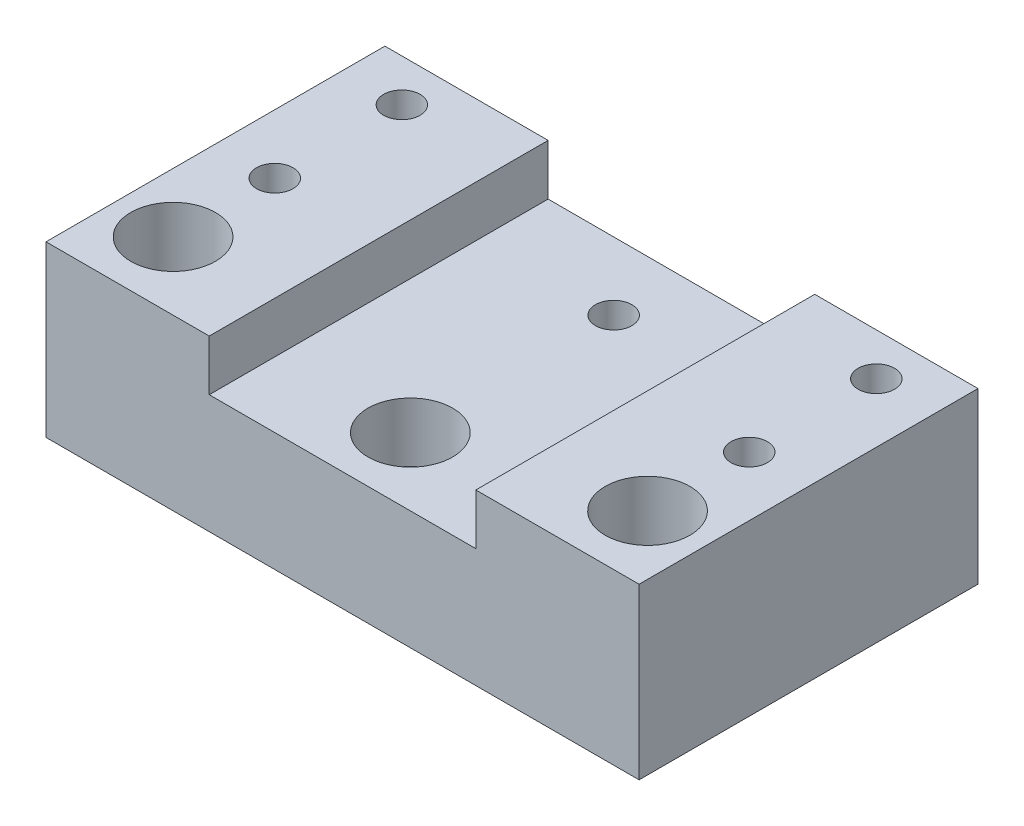
from build123d import *

# Parameters (mm, degrees)
AUFSATZ_LINEAR_AUSTRAGEN1_DEPTH  = 40
DURCHGANGSLOCH_F_R_M41_D         = 4.3
DURCHGANGSLOCH_F_R_M42_D         = 4.3
F_5_3_5_3_DURCHMESSER_BOHRUNG1_D = 5.3
DURCHGANGSLOCH_F_R_M81_D         = 8.4
SKIZZE26_R                       = 5
SCHNITT_LINEAR_AUSTRAGEN3_DEPTH  = 12
SKIZZE27_R                       = 5
SCHNITT_LINEAR_AUSTRAGEN4_DEPTH  = 7


with BuildPart() as part:
    # Skizze1 → Aufsatz-Linear austragen1 (new body)
    with BuildSketch(Plane.XY):
        Polygon((-85.072105864, 34.368747103), (-85.072105864, 14.368747103), (-50.072105864, 14.368747103), (-50.072105864, 28.368747103), (-65.805439197, 28.368747103), (-65.805439197, 34.368747103), align=None)
        Polygon((-50.072105864, 28.368747103), (-50.072105864, 14.368747103), (-15.072105864, 14.368747103), (-15.072105864, 34.368747103), (-34.33877253, 34.368747103), (-34.33877253, 28.368747103), align=None)
    extrude(amount=AUFSATZ_LINEAR_AUSTRAGEN1_DEPTH)

    # Durchgangsloch für M41 (through all)
    with Locations(Plane(origin=(0, 28.368747103, 0), x_dir=(1, 0, 0), z_dir=(0, 1, 0))):
        with Locations((-50.072105864, -8)):
            Hole(DURCHGANGSLOCH_F_R_M41_D / 2)

    # Durchgangsloch für M42 (through all)
    with Locations(Plane(origin=(0, 34.368747103, 0), x_dir=(1, 0, 0), z_dir=(0, 1, 0))):
        with Locations((-78.072105864, -5), (-78.072105864, -20), (-22.072105864, -20), (-22.072105864, -5)):
            Hole(DURCHGANGSLOCH_F_R_M42_D / 2)

    # Ø5.3 (5.3) Durchmesser Bohrung1 (through all)
    with Locations(Plane(origin=(0, 34.368747103, 0), x_dir=(1, 0, 0), z_dir=(0, 1, 0))):
        with Locations((-78.072105864, -32), (-22.072105864, -32)):
            Hole(F_5_3_5_3_DURCHMESSER_BOHRUNG1_D / 2)

    # Durchgangsloch für M81 (through all)
    with Locations(Plane(origin=(0, 28.368747103, 0), x_dir=(1, 0, 0), z_dir=(0, 1, 0))):
        with Locations((-50.072105864, -32)):
            Hole(DURCHGANGSLOCH_F_R_M81_D / 2)

    # Skizze26 → Schnitt-Linear austragen3 (cut)
    with BuildSketch(Plane(origin=(0, 34.368747103, 0), x_dir=(1, 0, 0), z_dir=(0, 1, 0))):
        with Locations((-78.072105864, -32)):
            Circle(SKIZZE26_R)
        with Locations((-22.072105864, -32)):
            Circle(SKIZZE26_R)
    extrude(amount=-SCHNITT_LINEAR_AUSTRAGEN3_DEPTH, mode=Mode.SUBTRACT)

    # Skizze27 → Schnitt-Linear austragen4 (cut)
    with BuildSketch(Plane(origin=(0, 28.368747103, 0), x_dir=(1, 0, 0), z_dir=(0, 1, 0))):
        with Locations((-50.072105864, -32)):
            Circle(SKIZZE27_R)
    extrude(amount=-SCHNITT_LINEAR_AUSTRAGEN4_DEPTH, mode=Mode.SUBTRACT)


solid = part.part
